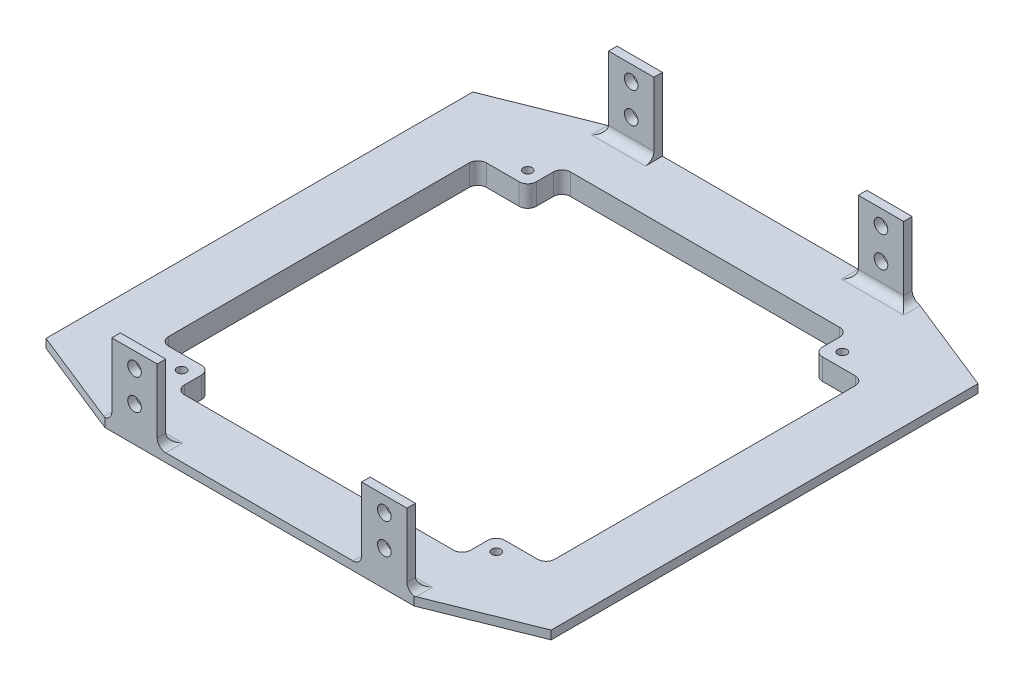
from build123d import *

# Parameters (mm, degrees)
BOSS_EXTRUDE1_DEPTH     = 2.25
BOSS_EXTRUDE2_DEPTH     = 1.5
CUT_EXTRUDE1_DEPTH      = 4.75
CUT_EXTRUDE1_DEPTH_BACK = 4.75
BOSS_EXTRUDE3_START     = 44.5
SKETCH5_W               = 8
SKETCH5_H               = 12.8
BOSS_EXTRUDE3_DEPTH     = 1.5
BOSS_EXTRUDE4_START     = -44.5
SKETCH5_2_W             = 8
SKETCH5_2_H             = 12.8
BOSS_EXTRUDE4_DEPTH     = 1.5
SKETCH6_R               = 1.2
CUT_EXTRUDE3_DEPTH      = 45.5
CUT_EXTRUDE3_DEPTH_BACK = 45.5
FILLET1_R               = 1.5
SKETCH7_W               = 89
SKETCH7_H               = 89
CUT_EXTRUDE4_DEPTH      = 4.75
BOSS_EXTRUDE5_DEPTH     = 3.75
FILLET2_R               = 1.5
M2X0_4_TAPPED_HOLE1_D   = 1.6


with BuildPart() as part:
    # Sketch1 → Boss-Extrude1 (new body, symmetric)
    with BuildSketch(Plane(origin=(0, 0, 0), x_dir=(1, 0, 0), z_dir=(0, 1, 0))):
        Polygon((-25.5, -35.5), (25.5, -35.5), (35.5, -31.5), (35.5, 31.5), (25.5, 35.5), (-25.5, 35.5), (-35.5, 31.5), (-35.5, -31.5), align=None)
    extrude(amount=BOSS_EXTRUDE1_DEPTH, both=True)

    # Sketch2 → Boss-Extrude2 (add)
    with BuildSketch(Plane(origin=(0, 2.25, 0), x_dir=(1, 0, 0), z_dir=(0, 1, 0))):
        Polygon((27.233241632, -44.5), (44.5, -37.593296653), (44.5, 37.593296653), (27.233241632, 44.5), (-27.233241632, 44.5), (-44.5, 37.593296653), (-44.5, -37.593296653), (-27.233241632, -44.5), align=None)
    boss_extrude2 = extrude(amount=BOSS_EXTRUDE2_DEPTH)

    # Mirror1: Boss-Extrude2 across plane
    add(boss_extrude2.mirror(Plane.ZX))

    # Sketch3 → Cut-Extrude1 (cut, two sides)
    with BuildSketch(Plane(origin=(0, 0, 0), x_dir=(1, 0, 0), z_dir=(0, 1, 0))) as cut_extrude1_sk:
        Polygon((-25.211126395, -34), (25.211126395, -34), (34, -30.484450558), (34, 30.484450558), (25.211126395, 34), (-25.211126395, 34), (-34, 30.484450558), (-34, -30.484450558), align=None)
    extrude(amount=CUT_EXTRUDE1_DEPTH, mode=Mode.SUBTRACT)
    extrude(cut_extrude1_sk.sketch, amount=-CUT_EXTRUDE1_DEPTH_BACK, mode=Mode.SUBTRACT)

    # Sketch5 → Boss-Extrude3 (add)
    with BuildSketch(Plane.XY.offset(BOSS_EXTRUDE3_START)):
        with Locations((-22, 10.15)):
            Rectangle(SKETCH5_W, SKETCH5_H)
        with Locations((22, 10.15)):
            Rectangle(SKETCH5_W, SKETCH5_H)
    extrude(amount=-BOSS_EXTRUDE3_DEPTH)

    # Sketch5_2 → Boss-Extrude4 (add)
    with BuildSketch(Plane.XY.offset(BOSS_EXTRUDE4_START)):
        with Locations((-22, 10.15)):
            Rectangle(SKETCH5_2_W, SKETCH5_2_H)
        with Locations((22, 10.15)):
            Rectangle(SKETCH5_2_W, SKETCH5_2_H)
    extrude(amount=BOSS_EXTRUDE4_DEPTH)

    # Sketch6 → Cut-Extrude3 (cut, two sides)
    with BuildSketch(Plane.XY) as cut_extrude3_sk:
        with Locations((-22, 13.85)):
            Circle(SKETCH6_R)
        with Locations((22, 13.85)):
            Circle(SKETCH6_R)
        with Locations((-22, 8.45)):
            Circle(SKETCH6_R)
        with Locations((22, 8.45)):
            Circle(SKETCH6_R)
    extrude(amount=CUT_EXTRUDE3_DEPTH, mode=Mode.SUBTRACT)
    extrude(cut_extrude3_sk.sketch, amount=-CUT_EXTRUDE3_DEPTH_BACK, mode=Mode.SUBTRACT)

    # Fillet1
    fillet1_edges = [part.edges().sort_by_distance(p)[0] for p in [
        (35.5, 0, 31.5),
        (25.5, 0, 35.5),
        (0, 2.25, -35.5),
        (0, -2.25, -35.5),
        (35.5, 2.25, 0),
        (35.5, -2.25, 0),
        (-35.5, 2.25, 0),
        (-35.5, -2.25, 0),
        (0, 2.25, 35.5),
        (0, -2.25, 35.5),
        (-25.5, 0, -35.5),
        (-30.5, 2.25, -33.5),
        (-35.5, 0, -31.5),
        (-30.5, -2.25, -33.5),
        (35.5, 0, -31.5),
        (30.5, 2.25, -33.5),
        (25.5, 0, -35.5),
        (30.5, -2.25, -33.5),
        (30.5, 2.25, 33.5),
        (30.5, -2.25, 33.5),
        (-35.5, 0, 31.5),
        (-30.5, 2.25, 33.5),
        (-25.5, 0, 35.5),
        (-30.5, -2.25, 33.5),
        (-22, 3.75, -43),
        (22, 3.75, -43),
        (-22, 3.75, 43),
        (22, 3.75, 43),
        (26, 3.75, 43.75),
        (-18, 3.75, 43.75),
        (18, 3.75, 43.75),
        (-26, 3.75, 43.75),
        (18, 3.75, -43.75),
        (26, 3.75, -43.75),
        (-26, 3.75, -43.75),
    ]]
    fillet(fillet1_edges, radius=FILLET1_R)

    # Sketch7 → Cut-Extrude4 (cut, through all)
    with BuildSketch(Plane(origin=(0, 0, 0), x_dir=(1, 0, 0), z_dir=(0, 1, 0))):
        Rectangle(SKETCH7_W, SKETCH7_H)
    extrude(amount=-CUT_EXTRUDE4_DEPTH, mode=Mode.SUBTRACT)

    # Sketch8 → Boss-Extrude5 (add)
    with BuildSketch(Plane(origin=(0, 0, 0), x_dir=(1, 0, 0), z_dir=(0, 1, 0))):
        Polygon((-25.211126395, -34), (-34, -30.484450558), (-34, -27.984450558), (-25.211126395, -27.984450558), align=None)
        Polygon((25.211126395, -27.984450558), (25.211126395, -34), (34, -30.484450558), (34, -27.984450558), align=None)
        Polygon((25.211126395, 34), (34, 30.484450558), (34, 27.984450558), (25.211126395, 27.984450558), align=None)
        Polygon((-25.211126395, 27.984450558), (-25.211126395, 34), (-34, 30.484450558), (-34, 27.984450558), align=None)
    extrude(amount=BOSS_EXTRUDE5_DEPTH)

    # Fillet2
    fillet2_edges = [part.edges().sort_by_distance(p)[0] for p in [
        (25.211126395, 1.875, 34),
        (-25.211126395, 1.875, 34),
        (25.211126395, 1.875, -34),
        (-25.211126395, 1.875, -34),
        (-25.211126395, 1.875, 27.984450558),
        (-34, 1.875, 27.984450558),
        (34, 1.875, 27.984450558),
        (25.211126395, 1.875, 27.984450558),
        (34, 1.875, -27.984450558),
        (25.211126395, 1.875, -27.984450558),
        (-34, 1.875, -27.984450558),
        (-25.211126395, 1.875, -27.984450558),
    ]]
    fillet(fillet2_edges, radius=FILLET2_R)

    # M2x0.4 Tapped Hole1 (through all)
    with Locations(Plane(origin=(0, 3.75, 0), x_dir=(1, 0, 0), z_dir=(0, 1, 0))):
        with Locations((-27.711126395, 30.484450558), (27.711126395, 30.484450558), (27.711126395, -30.484450558), (-27.711126395, -30.484450558)):
            Hole(M2X0_4_TAPPED_HOLE1_D / 2)


solid = part.part
